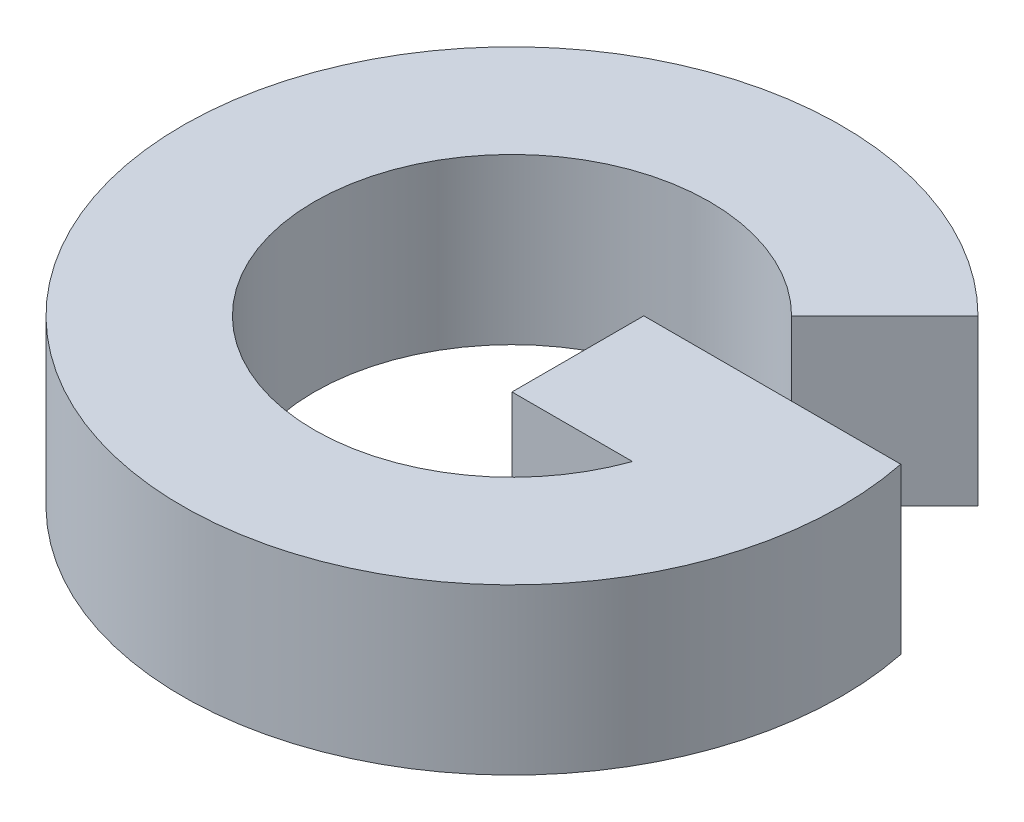
from build123d import *

# Parameters (mm, degrees)
BOSS_EXTRUDE1_DEPTH = 10


with BuildPart() as part:
    # Sketch1 → Boss-Extrude1 (new body)
    with BuildSketch(Plane(origin=(0, 0, 0), x_dir=(1, 0, 0), z_dir=(0, 1, 0))):
        with BuildLine():
            Line((328.485281374, 28.485281374), (334.142135624, 34.142135624))
            ThreePointArc((334.142135624, 34.142135624), (302.385239333, 10.527924903), (339.595917942, 24))
            Line((339.595917942, 24), (324, 24))
            Line((324, 24), (324, 16))
            Line((324, 16), (331.313708499, 16))
            ThreePointArc((331.313708499, 16), (308.296557654, 17.348691408), (328.485281374, 28.485281374))
        make_face()
    extrude(amount=BOSS_EXTRUDE1_DEPTH)


solid = part.part
